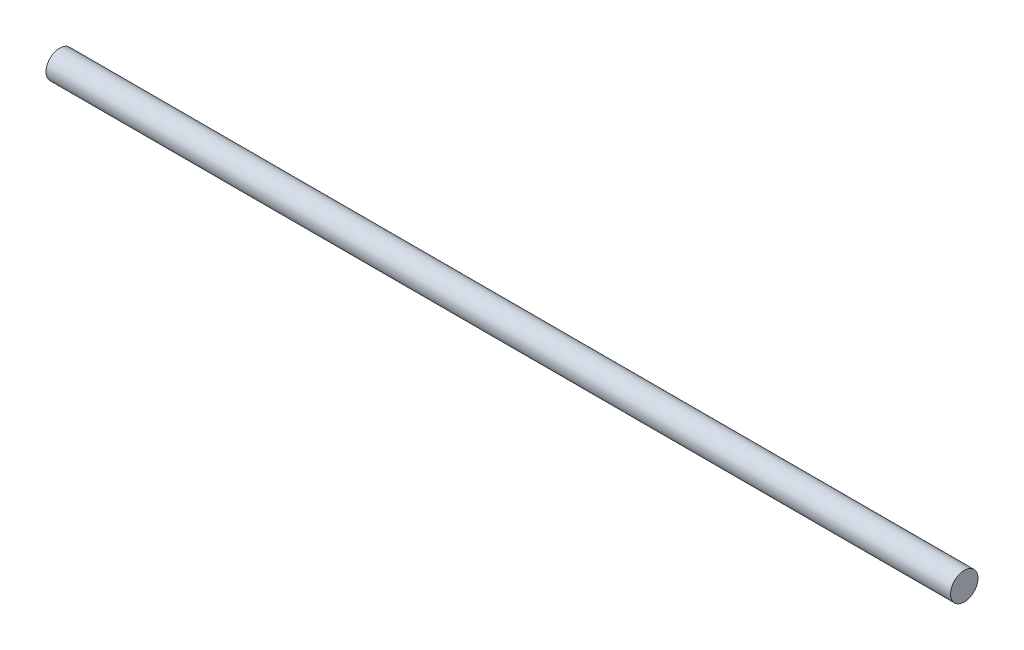
from build123d import *

# Parameters (mm, degrees)
SKETCH1_R           = 10.795
BOSS_EXTRUDE1_DEPTH = 355.6


with BuildPart() as part:
    # Sketch1 → Boss-Extrude1 (new body, symmetric)
    with BuildSketch(Plane(origin=(0, 0, 0), x_dir=(0, 0, -1), z_dir=(1, 0, 0))):
        Circle(SKETCH1_R)
    extrude(amount=BOSS_EXTRUDE1_DEPTH, both=True)


solid = part.part
